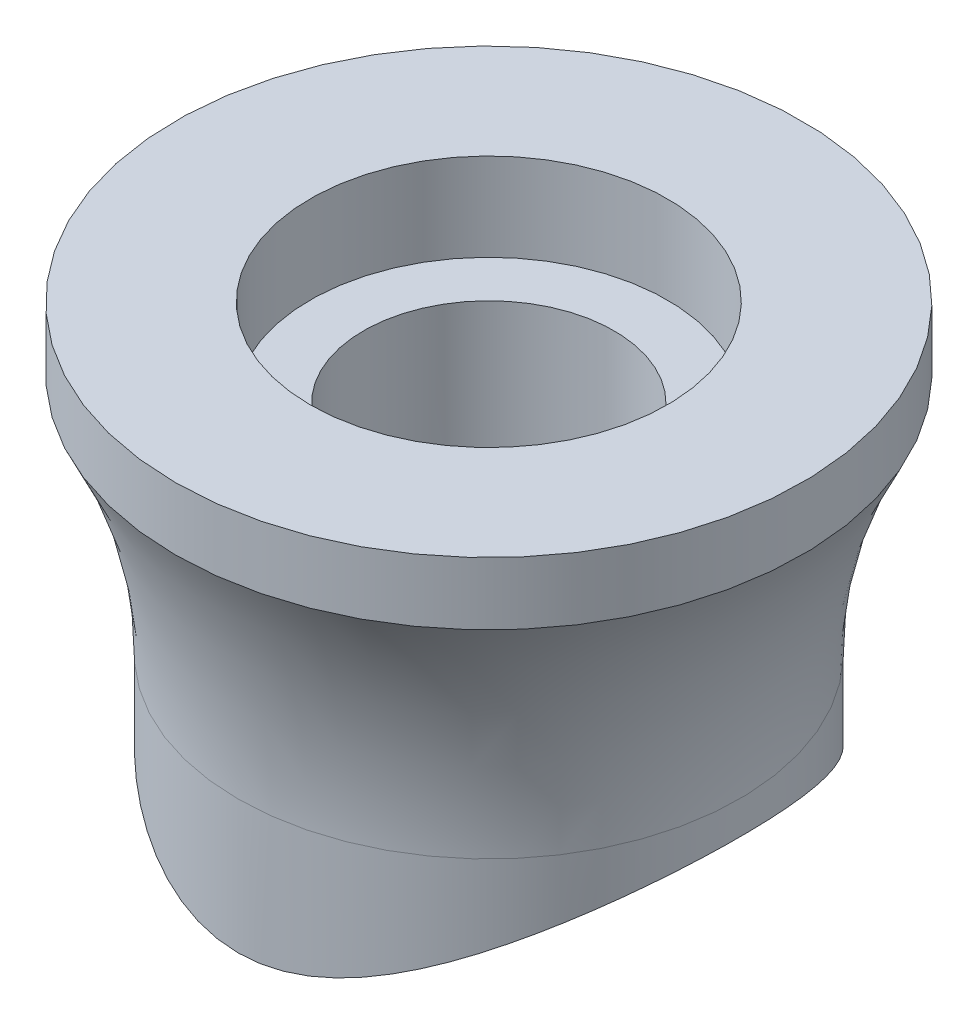
from build123d import *

# Parameters (mm, degrees)
ENL_V_MAT_EXTRU_1_DEPTH      = 26
ENL_V_MAT_EXTRU_1_DEPTH_BACK = 26


with BuildPart() as part:
    # Esquisse1 → Révolution1 (revolve)
    with BuildSketch(Plane.XY, mode=Mode.PRIVATE) as r_volution1_sk:
        with BuildLine():
            Line((10, -22), (10, -7))
            Line((10, -7), (14.25, -7))
            Line((14.25, -7), (14.25, 0))
            Line((14.25, 0), (25, 0))
            Line((25, 0), (25, -5))
            ThreePointArc((25, -5), (21.270166538, -14.364916731), (20, -24.364916731))
            Line((20, -24.364916731), (20, -35))
            Line((20, -35), (19.5, -35))
            Line((19.5, -35), (10, -22))
        make_face()
    revolve(r_volution1_sk.sketch.rotate(Axis((0, 35.983333333, 0), (0, -1, 0)), 90), axis=Axis((0, 35.983333333, 0), (0, -1, 0)))  # turned: the seam where the file's is

    # Esquisse2 → Enlèv. mat.-Extru.1 (cut, two sides)
    with BuildSketch(Plane(origin=(0, 0, 0), x_dir=(0, 0, -1), z_dir=(1, 0, 0))) as enl_v_mat_extru_1_sk:
        with BuildLine():
            Line((109.805806645, -120.529339662), (20, -35))
            ThreePointArc((20, -35), (0, -27), (-20, -35))
            Line((-20, -35), (-109.805806645, -120.529339662))
            Line((-109.805806645, -120.529339662), (-109.805806645, -368.564424682))
            Line((-109.805806645, -368.564424682), (109.805806645, -368.564424682))
            Line((109.805806645, -368.564424682), (109.805806645, -120.529339662))
        make_face()
    extrude(amount=ENL_V_MAT_EXTRU_1_DEPTH, mode=Mode.SUBTRACT)
    extrude(enl_v_mat_extru_1_sk.sketch, amount=-ENL_V_MAT_EXTRU_1_DEPTH_BACK, mode=Mode.SUBTRACT)


solid = part.part
